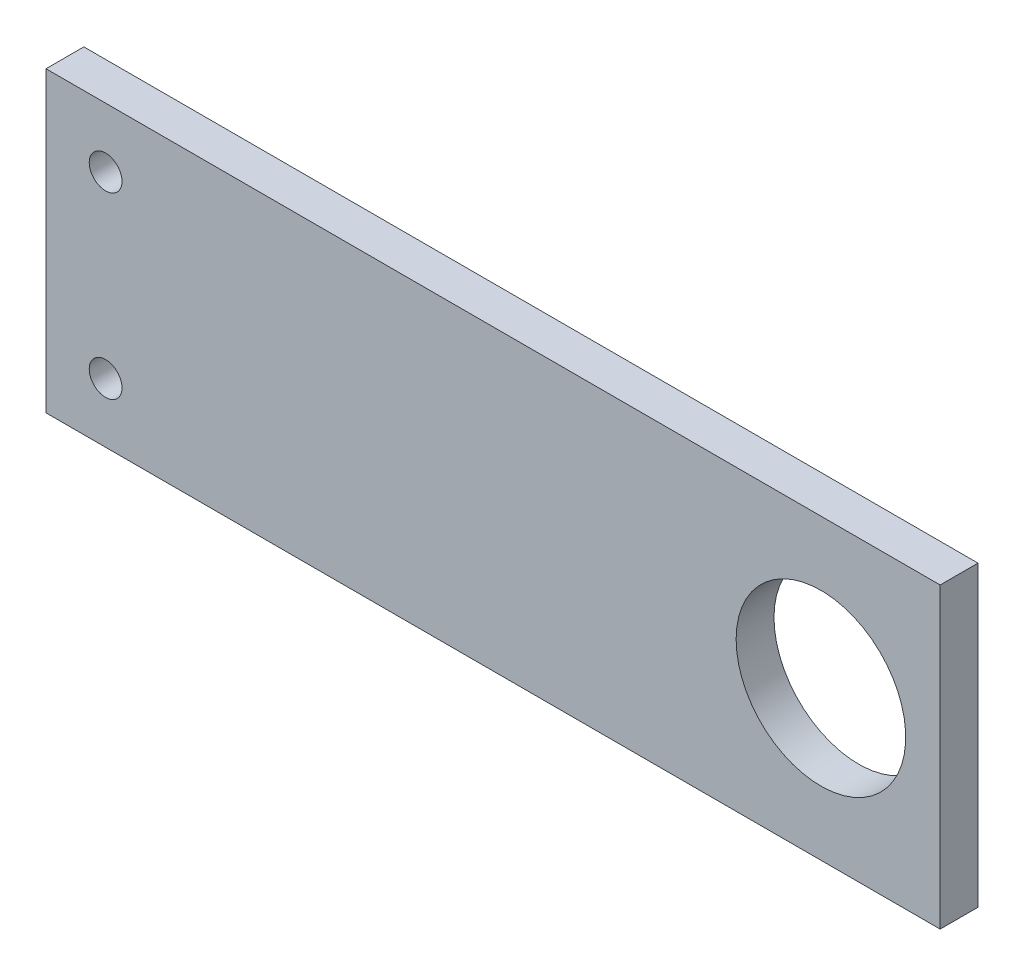
from build123d import *

# Parameters (mm, degrees)
SKETCH1_W           = 150
SKETCH1_H           = 50
BOSS_EXTRUDE1_DEPTH = 6.35
SKETCH2_R           = 14.225
CUT_EXTRUDE1_DEPTH  = 7.35
SKETCH3_R           = 2.75
CUT_EXTRUDE2_DEPTH  = 7.35


with BuildPart() as part:
    # Sketch1 → Boss-Extrude1 (new body)
    with BuildSketch(Plane.XY):
        with Locations((75, -25)):
            Rectangle(SKETCH1_W, SKETCH1_H)
    extrude(amount=BOSS_EXTRUDE1_DEPTH)

    # Sketch2 → Cut-Extrude1 (cut, through all)
    with BuildSketch(Plane(origin=(0, 0, 0), x_dir=(-1, 0, 0), z_dir=(0, 0, -1))):
        with Locations((-130, -25)):
            Circle(SKETCH2_R)
    extrude(amount=-CUT_EXTRUDE1_DEPTH, mode=Mode.SUBTRACT)

    # Sketch3 → Cut-Extrude2 (cut, through all)
    with BuildSketch(Plane(origin=(0, 0, 0), x_dir=(-1, 0, 0), z_dir=(0, 0, -1))):
        with Locations((-10, -10)):
            Circle(SKETCH3_R)
        with Locations((-10, -40)):
            Circle(SKETCH3_R)
    extrude(amount=-CUT_EXTRUDE2_DEPTH, mode=Mode.SUBTRACT)


solid = part.part
